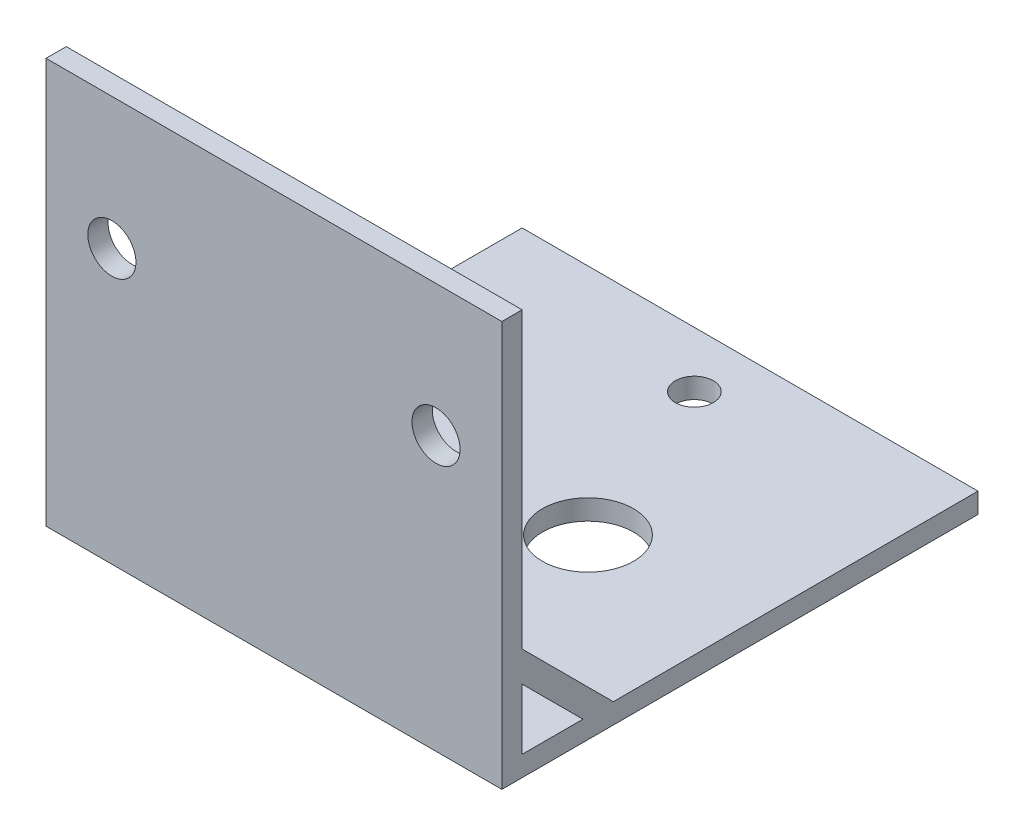
from build123d import *

# Parameters (mm, degrees)
SKETCH7_W           = 45
SKETCH7_H           = 45
SKETCH7_R           = 1.875
SKETCH7_R_2         = 4.5
BOSS_EXTRUDE5_DEPTH = 2
SKETCH7_3_W         = 45
SKETCH7_3_H         = 2
BOSS_EXTRUDE6_DEPTH = 40
BOSS_EXTRUDE7_DEPTH = 2
SKETCH10_R          = 2.375
CUT_EXTRUDE2_DEPTH  = 5


with BuildPart() as part:
    # Sketch7 → Boss-Extrude5 (new body)
    with BuildSketch(Plane(origin=(0, 0, 0), x_dir=(1, 0, 0), z_dir=(0, 1, 0))):
        with Locations((5.756289545, -118.050969126)):
            Rectangle(SKETCH7_W, SKETCH7_H)
        with Locations((5.756289545, -136.050969126)):
            Circle(SKETCH7_R, mode=Mode.SUBTRACT)
        with Locations((5.756289545, -101.050969126)):
            Circle(SKETCH7_R, mode=Mode.SUBTRACT)
        with Locations((12.756289545, -118.550969126)):
            Circle(SKETCH7_R_2, mode=Mode.SUBTRACT)
    extrude(amount=BOSS_EXTRUDE5_DEPTH)

    # Sketch7_3 → Boss-Extrude6 (add)
    with BuildSketch(Plane(origin=(0, 0, 0), x_dir=(1, 0, 0), z_dir=(0, 1, 0))):
        with Locations((5.756289545, -141.550969126)):
            Rectangle(SKETCH7_3_W, SKETCH7_3_H)
    extrude(amount=BOSS_EXTRUDE6_DEPTH)

    # Sketch8 → Boss-Extrude7 (add)
    with BuildSketch(Plane.ZY.offset(16.743710455)):
        Polygon((140.550969126, 8), (134.550969126, 2), (131.550969126, 2), (140.550969126, 11), align=None)
    boss_extrude7 = extrude(amount=-BOSS_EXTRUDE7_DEPTH)

    # Mirror2: Boss-Extrude7 across plane
    add(boss_extrude7.mirror(Plane.ZY.offset(-5.756289545)))

    # Sketch10 → Cut-Extrude2 (cut)
    with BuildSketch(Plane.XY.offset(142.550969126)):
        with Locations((21.756289545, 27)):
            Circle(SKETCH10_R)
        with Locations((-10.243710455, 27)):
            Circle(SKETCH10_R)
    extrude(amount=-CUT_EXTRUDE2_DEPTH, mode=Mode.SUBTRACT)


solid = part.part
